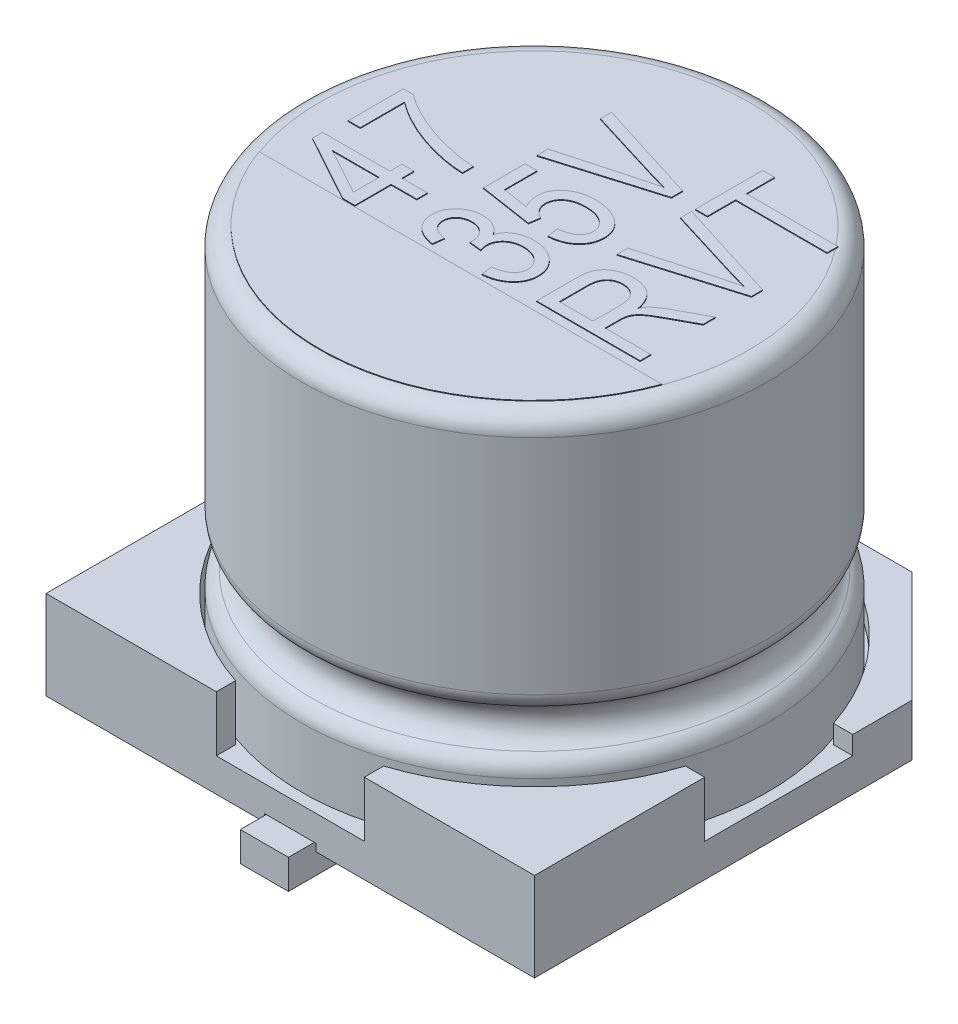
from build123d import *

# Parameters (mm, degrees)
SKETCH1_W                = 6.6
SKETCH1_H                = 6.6
BOSS_EXTRUDE1_DEPTH      = 1.2
CUT_EXTRUDE1_DEPTH       = 0.75
SKETCH3_W                = 3.3
SKETCH3_H                = 0.5
CUT_EXTRUDE2_DEPTH       = 5.902040392
CUT_EXTRUDE2_DEPTH_BACK  = 5.902040392
CHAMFER1_SIZE            = 1.5
CUT_EXTRUDE3_DEPTH       = 0.1
BOSS_EXTRUDE4_DEPTH      = 0.3
BOSS_EXTRUDE4_DEPTH_BACK = 0.1
SKETCH8_R                = 0.5
BOSS_EXTRUDE5_DEPTH      = 0.3
BOSS_EXTRUDE7_DEPTH      = 0.01


with BuildPart() as part:
    # Sketch1 → Boss-Extrude1 (new body)
    with BuildSketch(Plane(origin=(0, 0.3, 0), x_dir=(1, 0, 0), z_dir=(0, 1, 0))):
        Rectangle(SKETCH1_W, SKETCH1_H)
    extrude(amount=BOSS_EXTRUDE1_DEPTH)

    # Sketch2 → Cut-Extrude1 (cut)
    with BuildSketch(Plane(origin=(0, 1.5, 0), x_dir=(1, 0, 0), z_dir=(0, 1, 0))):
        with BuildLine():
            Line((-3.3, 1), (-3.039736831, 1))
            ThreePointArc((-3.039736831, 1), (-2.2627417, 2.2627417), (-1, 3.039736831))
            Line((-1, 3.039736831), (-1, 3.3))
            Line((-1, 3.3), (1, 3.3))
            Line((1, 3.3), (1, 3.039736831))
            ThreePointArc((1, 3.039736831), (2.2627417, 2.2627417), (3.039736831, 1))
            Line((3.039736831, 1), (3.3, 1))
            Line((3.3, 1), (3.3, -1))
            Line((3.3, -1), (3.039736831, -1))
            ThreePointArc((3.039736831, -1), (2.2627417, -2.2627417), (1, -3.039736831))
            Line((1, -3.039736831), (1, -3.3))
            Line((1, -3.3), (-1, -3.3))
            Line((-1, -3.3), (-1, -3.039736831))
            ThreePointArc((-1, -3.039736831), (-2.2627417, -2.2627417), (-3.039736831, -1))
            Line((-3.039736831, -1), (-3.3, -1))
            Line((-3.3, -1), (-3.3, 1))
        make_face()
    extrude(amount=-CUT_EXTRUDE1_DEPTH, mode=Mode.SUBTRACT)

    # Sketch3 → Cut-Extrude2 (cut, two sides)
    with BuildSketch(Plane(origin=(0, 0, 0), x_dir=(0, 0, -1), z_dir=(1, 0, 0))) as cut_extrude2_sk:
        with Locations((1.65, 1.25)):
            Rectangle(SKETCH3_W, SKETCH3_H)
    extrude(amount=CUT_EXTRUDE2_DEPTH, mode=Mode.SUBTRACT)
    extrude(cut_extrude2_sk.sketch, amount=-CUT_EXTRUDE2_DEPTH_BACK, mode=Mode.SUBTRACT)

    # Chamfer1
    chamfer1_edges = [part.edges().sort_by_distance(p)[0] for p in [
        (3.3, 0.65, -3.3),
        (-3.3, 0.65, -3.3),
    ]]
    chamfer(chamfer1_edges, length=CHAMFER1_SIZE)

    # Sketch7 → Cut-Extrude3 (cut)
    with BuildSketch(Plane.XZ.offset(-0.3)):
        with BuildLine():
            Line((-0.35, 3.3), (0.35, 3.3))
            Line((0.35, 3.3), (0.498675617, 1.261367968))
            ThreePointArc((0.498675617, 1.261367968), (0, 0.725), (-0.498675617, 1.261367968))
            Line((-0.498675617, 1.261367968), (-0.35, 3.3))
        make_face()
        with BuildLine():
            Line((-0.35, -3.3), (0.35, -3.3))
            Line((0.35, -3.3), (0.498675617, -1.261367968))
            ThreePointArc((0.498675617, -1.261367968), (0, -0.725), (-0.498675617, -1.261367968))
            Line((-0.498675617, -1.261367968), (-0.35, -3.3))
        make_face()
    extrude(amount=-CUT_EXTRUDE3_DEPTH, mode=Mode.SUBTRACT)

    # Sketch6 → Boss-Extrude4 (add, two sides)
    with BuildSketch(Plane.XZ.offset(-0.3)) as boss_extrude4_sk:
        with BuildLine():
            Line((-0.325, -1.225), (-0.325, -3.65))
            Line((-0.325, -3.65), (0.325, -3.65))
            Line((0.325, -3.65), (0.325, -1.225))
            ThreePointArc((0.325, -1.225), (0, -0.9), (-0.325, -1.225))
        make_face()
        with BuildLine():
            Line((-0.325, 1.225), (-0.325, 3.65))
            Line((-0.325, 3.65), (0.325, 3.65))
            Line((0.325, 3.65), (0.325, 1.225))
            ThreePointArc((0.325, 1.225), (0, 0.9), (-0.325, 1.225))
        make_face()
    extrude(amount=BOSS_EXTRUDE4_DEPTH)
    extrude(boss_extrude4_sk.sketch, amount=-BOSS_EXTRUDE4_DEPTH_BACK)

    # Sketch8 → Boss-Extrude5 (add)
    with BuildSketch(Plane.XZ.offset(-0.3)):
        with Locations(Location((-2, 2, 0), (0, 0, 270))):
            Circle(SKETCH8_R)
        with Locations(Location((2, 2, 0), (0, 0, 270))):
            Circle(SKETCH8_R)
        with Locations(Location((2, -2, 0), (0, 0, 270))):
            Circle(SKETCH8_R)
        with Locations(Location((-2, -2, 0), (0, 0, 270))):
            Circle(SKETCH8_R)
    extrude(amount=BOSS_EXTRUDE5_DEPTH)


with BuildPart() as body_2:
    # Sketch4 → Revolve1 (revolve)
    with BuildSketch(Plane(origin=(0, 0, 0), x_dir=(0, 0, -1), z_dir=(1, 0, 0)), mode=Mode.PRIVATE) as revolve1_sk:
        with BuildLine():
            Line((0, 0.75), (0, 5.8))
            Line((0, 5.8), (-2.9, 5.8))
            ThreePointArc((-2.9, 5.8), (-3.076776695, 5.726776695), (-3.15, 5.55))
            Line((-3.15, 5.55), (-3.15, 2.539897949))
            ThreePointArc((-3.15, 2.539897949), (-3.113200716, 2.409339707), (-3.013636364, 2.317217063))
            ThreePointArc((-3.013636364, 2.317217063), (-2.85, 2.05), (-3.013636364, 1.782782937))
            ThreePointArc((-3.013636364, 1.782782937), (-3.113200716, 1.690660293), (-3.15, 1.560102051))
            Line((-3.15, 1.560102051), (-3.15, 0.75))
            Line((-3.15, 0.75), (0, 0.75))
        make_face()
    revolve(revolve1_sk.sketch.rotate(Axis((0, 0, 0), (0, 1, 0)), 180), axis=Axis((0, 0, 0), (0, 1, 0)))

    # Sketch10 → Boss-Extrude7 (add)
    with BuildSketch(Plane(origin=(0, 5.8, 0), x_dir=(1, 0, 0), z_dir=(0, 1, 0))):
        with BuildLine():
            Line((-2.722131518, -1), (2.722131518, -1))
            ThreePointArc((2.722131518, -1), (0, -2.9), (-2.722131518, -1))
        make_face()
        Polygon((-1.1, -0.490909091), (-1.445454545, -0.490909091), (-1.445454545, -0.981818182), (-1.609090909, -0.981818182), (-2.518181818, -0.482670455), (-2.518181818, -0.345454545), (-1.609090909, -0.345454545), (-1.609090909, -0.181818182), (-1.445454545, -0.181818182), (-1.445454545, -0.345454545), (-1.1, -0.345454545), align=None)
        Polygon((-1.609090909, -0.490909091), (-2.241761364, -0.490909091), (-1.609090909, -0.838352273), align=None, mode=Mode.SUBTRACT)
        with BuildLine():
            Line((-2.318181818, -0.036363636), (-2.481818182, -0.036363636))
            Line((-2.481818182, -0.036363636), (-2.481818182, 0.709090909))
            Line((-2.481818182, 0.709090909), (-2.348011364, 0.709090909))
            add(Edge.make_bspline(
                [(-2.348011364, 0.709090909), (-2.329493997, 0.695259816), (-2.291802758, 0.667107268), (-2.231511589, 0.627736674), (-2.167300458, 0.589447284), (-2.099115474, 0.552202178), (-2.026735965, 0.516442976), (-1.950395077, 0.481792677), (-1.869863353, 0.448671938), (-1.786180255, 0.416771358), (-1.700509186, 0.387072726), (-1.614166454, 0.360699392), (-1.527962748, 0.337560436), (-1.441958888, 0.318119267), (-1.356259293, 0.301430866), (-1.270766825, 0.288433289), (-1.185381408, 0.278624638), (-1.128427711, 0.274690798), (-1.1, 0.272727273)],
                knots=[0, 0, 0, 0, 0.828228242, 1.685820058, 2.579325365, 3.507361607, 4.469713273, 5.472243924, 6.511632332, 7.590183537, 8.68180921, 9.76082494, 10.825356942, 11.880104434, 12.920528634, 13.95402052, 14.978775448, 16, 16, 16, 16], degree=3))
            Line((-1.1, 0.272727273), (-1.1, 0.127272727))
            add(Edge.make_bspline(
                [(-1.1, 0.127272727), (-1.114968384, 0.127721783), (-1.145503887, 0.128637858), (-1.192187637, 0.132321595), (-1.240736039, 0.136926159), (-1.291101377, 0.14395977), (-1.343309321, 0.152404131), (-1.397339203, 0.16282712), (-1.453308412, 0.174269157), (-1.530001628, 0.192613669), (-1.62599912, 0.218383212), (-1.739052852, 0.255716866), (-1.849665888, 0.297377526), (-1.956248385, 0.345139752), (-2.057722591, 0.395822213), (-2.151901767, 0.449612447), (-2.239097534, 0.503996466), (-2.292310728, 0.544126176), (-2.318181818, 0.563636364)],
                knots=[0, 0, 0, 0, 0.547560405, 1.117023226, 1.712128439, 2.330702075, 2.976322001, 3.646013224, 4.342857794, 5.065247493, 6.529539093, 7.976213993, 9.417556904, 10.850065343, 12.245478746, 13.563746768, 14.815546979, 16, 16, 16, 16], degree=3))
            Line((-2.318181818, 0.563636364), (-2.318181818, -0.036363636))
        make_face()
        with BuildLine():
            Line((0.218181818, -0.927272727), (0.2, -0.781818182))
            add(Edge.make_bspline(
                [(0.2, -0.781818182), (0.211007106, -0.779942216), (0.232455925, -0.776286646), (0.263321691, -0.769094104), (0.292204025, -0.761244122), (0.31883103, -0.75214582), (0.343462791, -0.742228405), (0.365942251, -0.73123066), (0.386265646, -0.718934775), (0.404444756, -0.705643407), (0.420565669, -0.691315503), (0.434522787, -0.67601624), (0.446306126, -0.659602334), (0.456112377, -0.642230253), (0.463387067, -0.623625086), (0.468939102, -0.604152393), (0.472027052, -0.583526059), (0.472490475, -0.5694225), (0.472727273, -0.562215909)],
                knots=[0, 0, 0, 0, 1.392235382, 2.712957193, 3.95076201, 5.123471921, 6.220028287, 7.260520794, 8.240826993, 9.178593426, 10.065213643, 10.926376853, 11.755607984, 12.580369742, 13.407158359, 14.241002189, 15.101193065, 16, 16, 16, 16], degree=3))
            add(Edge.make_bspline(
                [(0.472727273, -0.562215909), (0.472577298, -0.554333745), (0.472282519, -0.538841217), (0.467891068, -0.516137974), (0.461895744, -0.494080521), (0.452557801, -0.473049195), (0.441083833, -0.452673681), (0.427240736, -0.432928372), (0.410127195, -0.414589557), (0.391315379, -0.396729975), (0.370429846, -0.380261991), (0.347624201, -0.366047226), (0.323284305, -0.354172655), (0.297651287, -0.343941869), (0.270175187, -0.336935551), (0.24151094, -0.330948508), (0.211140838, -0.327994951), (0.190440289, -0.327517474), (0.179829545, -0.327272727)],
                knots=[0, 0, 0, 0, 0.90401877, 1.776864238, 2.648081008, 3.525187418, 4.41175602, 5.332444618, 6.287459433, 7.287987893, 8.31086095, 9.337199425, 10.368656826, 11.419214808, 12.501240718, 13.621372252, 14.780756564, 16, 16, 16, 16], degree=3))
            add(Edge.make_bspline(
                [(0.179829545, -0.327272727), (0.169880445, -0.327530349), (0.150509863, -0.328031929), (0.122176015, -0.330790698), (0.095332464, -0.335845419), (0.070052559, -0.343397933), (0.045946798, -0.352341479), (0.023507707, -0.363757347), (0.00260552, -0.377228214), (-0.016606513, -0.392470321), (-0.033934824, -0.409291249), (-0.049309229, -0.427056412), (-0.062233922, -0.445902217), (-0.072512687, -0.465824635), (-0.080790079, -0.486542866), (-0.086829101, -0.50823826), (-0.09027555, -0.530949186), (-0.090695173, -0.546389907), (-0.090909091, -0.554261364)],
                knots=[0, 0, 0, 0, 1.208597586, 2.353100882, 3.45394355, 4.52041929, 5.55433039, 6.572835576, 7.571467818, 8.570232532, 9.546354476, 10.500752408, 11.419554319, 12.314725937, 13.218209175, 14.125127028, 15.044216874, 16, 16, 16, 16], degree=3))
            add(Edge.make_bspline(
                [(-0.090909091, -0.554261364), (-0.090685115, -0.561378176), (-0.09020766, -0.576549262), (-0.086078588, -0.600438295), (-0.080275224, -0.626876002), (-0.074580449, -0.64502036), (-0.071590909, -0.654545455)],
                knots=[0, 0, 0, 0, 0.832645691, 1.774971563, 2.831945141, 4, 4, 4, 4], degree=3))
            Line((-0.071590909, -0.654545455), (-0.236363636, -0.636363636))
            Line((-0.236363636, -0.636363636), (-0.234375, -0.614488636))
            add(Edge.make_bspline(
                [(-0.234375, -0.614488636), (-0.234471562, -0.606047534), (-0.234659986, -0.58957609), (-0.238100642, -0.565479821), (-0.242716286, -0.542518495), (-0.249520119, -0.520775269), (-0.258591189, -0.500475604), (-0.268853361, -0.480958247), (-0.281935977, -0.463149348), (-0.296240178, -0.446273642), (-0.31255473, -0.431386896), (-0.32979079, -0.417768621), (-0.348738456, -0.406792048), (-0.36885059, -0.39747845), (-0.390353615, -0.39058779), (-0.41303568, -0.38527953), (-0.437057369, -0.382594554), (-0.453498447, -0.382081401), (-0.461931818, -0.381818182)],
                knots=[0, 0, 0, 0, 1.104751502, 2.155743671, 3.182513959, 4.171256571, 5.132373004, 6.092768569, 7.053244257, 8.020744794, 8.986334532, 9.941668794, 10.892724274, 11.847575109, 12.840124028, 13.845307576, 14.89476101, 16, 16, 16, 16], degree=3))
            add(Edge.make_bspline(
                [(-0.461931818, -0.381818182), (-0.477042, -0.382465495), (-0.506081067, -0.383709516), (-0.547490028, -0.393407956), (-0.584269346, -0.410010102), (-0.615585748, -0.43319223), (-0.640886334, -0.460842938), (-0.659391316, -0.492035416), (-0.670665785, -0.526328903), (-0.672031656, -0.550294637), (-0.672727273, -0.5625)],
                knots=[0, 0, 0, 0, 1.16832052, 2.245303051, 3.268291818, 4.269210926, 5.239185917, 6.148985104, 7.05730787, 8, 8, 8, 8], degree=3))
            add(Edge.make_bspline(
                [(-0.672727273, -0.5625), (-0.672136462, -0.575177442), (-0.670987129, -0.599839461), (-0.660065857, -0.635121915), (-0.643265499, -0.667459622), (-0.62338947, -0.691252383), (-0.604305971, -0.708061423), (-0.588001403, -0.719706286), (-0.570101021, -0.730321018), (-0.550244964, -0.73920806), (-0.528993695, -0.74778534), (-0.505599424, -0.753845761), (-0.480781666, -0.75990119), (-0.463475995, -0.762364948), (-0.454545455, -0.763636364)],
                knots=[0, 0, 0, 0, 1.388978158, 2.702043981, 4.01873002, 5.370445164, 6.077879322, 6.808188353, 7.568116439, 8.359222831, 9.195597867, 10.081410868, 11.009917745, 12, 12, 12, 12], degree=3))
            Line((-0.454545455, -0.763636364), (-0.472727273, -0.909090909))
            add(Edge.make_bspline(
                [(-0.472727273, -0.909090909), (-0.486588422, -0.906709187), (-0.513627385, -0.902063157), (-0.552534962, -0.892356516), (-0.588882675, -0.880804326), (-0.622470375, -0.866817395), (-0.653589647, -0.850935865), (-0.682109165, -0.83296739), (-0.708216168, -0.813146008), (-0.731189578, -0.790783101), (-0.751650837, -0.767015095), (-0.769321558, -0.741828188), (-0.78453133, -0.715671444), (-0.796784585, -0.688113739), (-0.806500844, -0.659413834), (-0.813300208, -0.62942803), (-0.817319761, -0.5983104), (-0.817891717, -0.577189816), (-0.818181818, -0.566477273)],
                knots=[0, 0, 0, 0, 1.259750421, 2.457396855, 3.589696629, 4.673763457, 5.713494597, 6.716289503, 7.690389722, 8.644478697, 9.583164327, 10.496506905, 11.397350125, 12.289843847, 13.194037124, 14.107891875, 15.040306322, 16, 16, 16, 16], degree=3))
            add(Edge.make_bspline(
                [(-0.818181818, -0.566477273), (-0.817849499, -0.555189393), (-0.817195712, -0.532982213), (-0.81216052, -0.500348199), (-0.804360335, -0.468940312), (-0.792829686, -0.438990922), (-0.778255688, -0.410272016), (-0.760170015, -0.382972618), (-0.7391088, -0.356770776), (-0.715081364, -0.332176141), (-0.688496941, -0.309862399), (-0.659952473, -0.290196602), (-0.629838405, -0.273227531), (-0.597699986, -0.259960811), (-0.564045505, -0.249401853), (-0.528783494, -0.241757044), (-0.491794021, -0.237063148), (-0.466586203, -0.236600346), (-0.453693182, -0.236363636)],
                knots=[0, 0, 0, 0, 0.987388499, 1.942536239, 2.883158237, 3.814277833, 4.744511983, 5.696058098, 6.674468722, 7.682403848, 8.699933891, 9.706744222, 10.712052869, 11.718590333, 12.743383256, 13.79503062, 14.872226231, 16, 16, 16, 16], degree=3))
            add(Edge.make_bspline(
                [(-0.453693182, -0.236363636), (-0.438125528, -0.236801256), (-0.407722128, -0.237655922), (-0.363619433, -0.245894), (-0.322243567, -0.258967805), (-0.283869742, -0.277202539), (-0.248695107, -0.299925141), (-0.217581104, -0.327217825), (-0.190001883, -0.358366016), (-0.175513292, -0.382049729), (-0.168181818, -0.394034091)],
                knots=[0, 0, 0, 0, 1.090109576, 2.128968013, 3.132278696, 4.123864162, 5.09769889, 6.057339906, 7.016980922, 8, 8, 8, 8], degree=3))
            add(Edge.make_bspline(
                [(-0.168181818, -0.394034091), (-0.164794643, -0.383025672), (-0.158176533, -0.361516618), (-0.143272883, -0.331843256), (-0.125965116, -0.304786209), (-0.105205177, -0.280610246), (-0.080986041, -0.259108107), (-0.053139537, -0.239908092), (-0.021399527, -0.223411796), (0.013442898, -0.208508231), (0.051362925, -0.196828759), (0.091602413, -0.187855507), (0.134149227, -0.182767109), (0.163244427, -0.182139281), (0.178125, -0.181818182)],
                knots=[0, 0, 0, 0, 0.945190562, 1.846782401, 2.71900073, 3.580139159, 4.456653473, 5.37426406, 6.352713278, 7.392141409, 8.485180558, 9.608884637, 10.777077804, 12, 12, 12, 12], degree=3))
            add(Edge.make_bspline(
                [(0.178125, -0.181818182), (0.193956497, -0.182100114), (0.224864479, -0.182650533), (0.270088329, -0.188280689), (0.313135099, -0.197047206), (0.35415735, -0.209071993), (0.392766093, -0.22525971), (0.429357749, -0.244501126), (0.463535233, -0.267692236), (0.495224314, -0.294050206), (0.523859571, -0.322740148), (0.549309456, -0.352951249), (0.570155465, -0.385048482), (0.588203791, -0.417955902), (0.601450887, -0.452723838), (0.611241954, -0.488666444), (0.616996865, -0.526141121), (0.617783261, -0.551590514), (0.618181818, -0.564488636)],
                knots=[0, 0, 0, 0, 1.16811134, 2.280514916, 3.358044357, 4.408548324, 5.43018962, 6.443354211, 7.455384821, 8.473000684, 9.481330986, 10.444351977, 11.382702375, 12.302115503, 13.209492159, 14.121756026, 15.048078649, 16, 16, 16, 16], degree=3))
            add(Edge.make_bspline(
                [(0.618181818, -0.564488636), (0.617863516, -0.576438512), (0.617236528, -0.599977211), (0.611995991, -0.634554935), (0.603386915, -0.667629385), (0.591834099, -0.699493451), (0.576205806, -0.729747753), (0.557507399, -0.758714121), (0.535301773, -0.786291731), (0.509949449, -0.812228909), (0.481552485, -0.835919572), (0.450949567, -0.857456509), (0.41801359, -0.876264186), (0.382414632, -0.891873127), (0.344657211, -0.904836633), (0.304626921, -0.91545202), (0.26225395, -0.923158475), (0.233076611, -0.925882258), (0.218181818, -0.927272727)],
                knots=[0, 0, 0, 0, 0.959215385, 1.889449177, 2.800558469, 3.700364268, 4.604976927, 5.528817283, 6.464628809, 7.443299003, 8.436397546, 9.430019983, 10.444889234, 11.476401659, 12.54654308, 13.647683262, 14.799161616, 16, 16, 16, 16], degree=3))
        make_face()
        with BuildLine():
            Line((0.218181818, -0.036363636), (0.2, 0.109090909))
            add(Edge.make_bspline(
                [(0.2, 0.109090909), (0.211101971, 0.110567587), (0.232737788, 0.113445378), (0.263885694, 0.119848382), (0.293064038, 0.126930845), (0.319651618, 0.136285915), (0.34447028, 0.146000707), (0.366780938, 0.157754603), (0.387216311, 0.170429338), (0.405044464, 0.184825644), (0.42111939, 0.19975374), (0.434636833, 0.215785653), (0.446561389, 0.232076172), (0.456229143, 0.249117635), (0.463723293, 0.266844238), (0.468775385, 0.285197267), (0.472033163, 0.304051607), (0.472494528, 0.316842721), (0.472727273, 0.323295455)],
                knots=[0, 0, 0, 0, 1.411589299, 2.750942728, 4.00771248, 5.193274551, 6.301848483, 7.364530321, 8.36815806, 9.328452501, 10.249032995, 11.129646394, 11.967965374, 12.7913576, 13.594060915, 14.387835106, 15.186711129, 16, 16, 16, 16], degree=3))
            add(Edge.make_bspline(
                [(0.472727273, 0.323295455), (0.47246113, 0.331363756), (0.471934427, 0.347331097), (0.46751459, 0.370816108), (0.460368895, 0.393421364), (0.450386963, 0.415271865), (0.43708047, 0.435936311), (0.421405758, 0.456119122), (0.402468066, 0.474980646), (0.381218628, 0.493183371), (0.357552586, 0.510017788), (0.331144397, 0.524080821), (0.302921326, 0.536308638), (0.27269317, 0.546702043), (0.240203605, 0.554209971), (0.20572194, 0.559481998), (0.169202922, 0.563055128), (0.1441377, 0.563438993), (0.13125, 0.563636364)],
                knots=[0, 0, 0, 0, 0.833503236, 1.64952068, 2.460650161, 3.279715081, 4.124353123, 4.995793989, 5.916428404, 6.881576056, 7.886415737, 8.911413223, 9.967990459, 11.063833818, 12.210651719, 13.409634283, 14.668120429, 16, 16, 16, 16], degree=3))
            add(Edge.make_bspline(
                [(0.13125, 0.563636364), (0.119216027, 0.563411231), (0.095769358, 0.56297259), (0.061609862, 0.559772504), (0.029473354, 0.554831228), (-0.000594739, 0.547469608), (-0.028423842, 0.537659446), (-0.054490961, 0.526502629), (-0.078298563, 0.512722984), (-0.099725125, 0.496779871), (-0.119111641, 0.479625248), (-0.135710672, 0.460896308), (-0.149925684, 0.441323642), (-0.161929936, 0.420707247), (-0.170475105, 0.398657339), (-0.177295763, 0.375820096), (-0.180872766, 0.351720796), (-0.181499254, 0.335331824), (-0.181818182, 0.326988636)],
                knots=[0, 0, 0, 0, 1.312040837, 2.556345105, 3.737883698, 4.854849349, 5.925960309, 6.952388988, 7.9424386, 8.917239489, 9.860521384, 10.760061641, 11.639947922, 12.495504232, 13.352616949, 14.212152034, 15.089854369, 16, 16, 16, 16], degree=3))
            add(Edge.make_bspline(
                [(-0.181818182, 0.326988636), (-0.181386991, 0.31691141), (-0.180526809, 0.296808367), (-0.173354012, 0.267203557), (-0.161919921, 0.238576183), (-0.145949551, 0.211277017), (-0.125781986, 0.186087196), (-0.101844533, 0.163424776), (-0.074502628, 0.143327785), (-0.054133578, 0.132693693), (-0.04375, 0.127272727)],
                knots=[0, 0, 0, 0, 0.943121662, 1.881431981, 2.836990949, 3.823036868, 4.833137184, 5.849762362, 6.903868453, 8, 8, 8, 8], degree=3))
            Line((-0.04375, 0.127272727), (-0.064488636, -0.018181818))
            Line((-0.064488636, -0.018181818), (-0.781818182, 0.090909091))
            Line((-0.781818182, 0.090909091), (-0.781818182, 0.654545455))
            Line((-0.781818182, 0.654545455), (-0.618181818, 0.654545455))
            Line((-0.618181818, 0.654545455), (-0.618181818, 0.212784091))
            Line((-0.618181818, 0.212784091), (-0.272443182, 0.160227273))
            add(Edge.make_bspline(
                [(-0.272443182, 0.160227273), (-0.280823021, 0.176613081), (-0.297407403, 0.209041926), (-0.314678944, 0.260640587), (-0.32533713, 0.313667947), (-0.326625365, 0.349571453), (-0.327272727, 0.367613636)],
                knots=[0, 0, 0, 0, 1.017619267, 2.013951072, 3.001973272, 4, 4, 4, 4], degree=3))
            add(Edge.make_bspline(
                [(-0.327272727, 0.367613636), (-0.326874523, 0.378906499), (-0.326083106, 0.401350674), (-0.320235417, 0.434343157), (-0.310874813, 0.466250024), (-0.297294668, 0.496922513), (-0.279916146, 0.526376693), (-0.258874387, 0.554832977), (-0.234130638, 0.58215363), (-0.205438517, 0.607756331), (-0.173874347, 0.631620275), (-0.139218461, 0.652454829), (-0.10193904, 0.670137284), (-0.061857834, 0.684168416), (-0.019379192, 0.695726579), (0.025894119, 0.703532212), (0.073772199, 0.708019966), (0.106524397, 0.708728234), (0.123295455, 0.709090909)],
                knots=[0, 0, 0, 0, 0.861018809, 1.711245113, 2.547675859, 3.391805506, 4.262674834, 5.151129072, 6.086914488, 7.068866089, 8.080081396, 9.100796714, 10.1476286, 11.221399762, 12.335728169, 13.501851446, 14.720800604, 16, 16, 16, 16], degree=3))
            add(Edge.make_bspline(
                [(0.123295455, 0.709090909), (0.139972763, 0.708744866), (0.172829781, 0.708063103), (0.221182639, 0.703234952), (0.267685748, 0.694930211), (0.312341106, 0.683620509), (0.355233532, 0.669108797), (0.396299037, 0.651153258), (0.435499753, 0.629784545), (0.472612172, 0.605560487), (0.506510629, 0.57857772), (0.53647709, 0.549082485), (0.561857129, 0.517280497), (0.582560215, 0.483088947), (0.598604448, 0.446704241), (0.609942787, 0.408034652), (0.616952086, 0.367110572), (0.617766217, 0.339043658), (0.618181818, 0.324715909)],
                knots=[0, 0, 0, 0, 1.144492614, 2.254837035, 3.330813134, 4.383755227, 5.413414698, 6.434919789, 7.455680344, 8.474121079, 9.472858394, 10.424138735, 11.353862604, 12.257787762, 13.159841921, 14.074912736, 15.017271142, 16, 16, 16, 16], degree=3))
            add(Edge.make_bspline(
                [(0.618181818, 0.324715909), (0.617828765, 0.312771431), (0.617133725, 0.289256917), (0.612395275, 0.254615174), (0.603577826, 0.221636349), (0.592442177, 0.189715236), (0.577096784, 0.15959834), (0.55888353, 0.130664995), (0.537105731, 0.103295459), (0.512134892, 0.077568051), (0.484458274, 0.053758215), (0.454005872, 0.032531418), (0.420992011, 0.014069776), (0.385306503, -0.001590372), (0.347111633, -0.014252186), (0.306479895, -0.024498815), (0.263297216, -0.032285998), (0.233456651, -0.03498306), (0.218181818, -0.036363636)],
                knots=[0, 0, 0, 0, 0.958689857, 1.887326147, 2.797936266, 3.6946441, 4.595336751, 5.504073741, 6.434636212, 7.396724143, 8.377688541, 9.360182663, 10.370759081, 11.408658253, 12.482955239, 13.5963024, 14.769591684, 16, 16, 16, 16], degree=3))
        make_face()
        with BuildLine():
            Line((0.6, 1.250852273), (-0.8, 0.832102273))
            Line((-0.8, 0.832102273), (-0.8, 0.981818182))
            Line((-0.8, 0.981818182), (0.215625, 1.261931818))
            add(Edge.make_bspline(
                [(0.215625, 1.261931818), (0.23502513, 1.267188611), (0.273113627, 1.277509333), (0.329419911, 1.291882434), (0.383540048, 1.305617864), (0.419023676, 1.314057553), (0.436363636, 1.318181818)],
                knots=[0, 0, 0, 0, 1.058778416, 2.078711773, 3.061114545, 4, 4, 4, 4], degree=3))
            add(Edge.make_bspline(
                [(0.436363636, 1.318181818), (0.400128509, 1.327526981), (0.326165891, 1.346602192), (0.252964299, 1.368417642), (0.215625, 1.379545455)],
                knots=[0, 0, 0, 0, 0.979822753, 2, 2, 2, 2], degree=3))
            Line((0.215625, 1.379545455), (-0.8, 1.690909091))
            Line((-0.8, 1.690909091), (-0.8, 1.842045455))
            Line((-0.8, 1.842045455), (0.6, 1.401136364))
            Line((0.6, 1.401136364), (0.6, 1.250852273))
        make_face()
        with BuildLine():
            Line((2.3, -0.872727273), (0.9, -0.872727273))
            Line((0.9, -0.872727273), (0.9, -0.358522727))
            add(Edge.make_bspline(
                [(0.9, -0.358522727), (0.900073763, -0.345546017), (0.900216539, -0.320428259), (0.902308959, -0.284044497), (0.905344787, -0.250202662), (0.909579597, -0.219012834), (0.914777868, -0.190483154), (0.921766894, -0.16473241), (0.929434889, -0.141402667), (0.942097141, -0.11394169), (0.962104286, -0.08285306), (0.991986148, -0.049045543), (1.029113573, -0.019546227), (1.071726678, 0.006727276), (1.11958402, 0.028297408), (1.17177175, 0.043578157), (1.22760849, 0.052802429), (1.266062455, 0.053954341), (1.285795455, 0.054545455)],
                knots=[0, 0, 0, 0, 0.957632509, 1.853596319, 2.688865688, 3.464800978, 4.176232129, 4.827248354, 5.432859936, 5.986426289, 7.054779681, 8.148885667, 9.301586196, 10.541074307, 11.836203864, 13.163061816, 14.544199576, 16, 16, 16, 16], degree=3))
            add(Edge.make_bspline(
                [(1.285795455, 0.054545455), (1.298871698, 0.054235333), (1.32441369, 0.053629569), (1.361855278, 0.049987367), (1.397440244, 0.043563031), (1.430988976, 0.034018043), (1.462814114, 0.022553984), (1.492482956, 0.007839851), (1.520425409, -0.009159596), (1.546408208, -0.028871174), (1.570251677, -0.051075165), (1.592091252, -0.075549512), (1.611022928, -0.102851103), (1.628180904, -0.132133088), (1.642985373, -0.163902878), (1.65548257, -0.198004739), (1.665367052, -0.234558689), (1.67023708, -0.259813647), (1.672727273, -0.272727273)],
                knots=[0, 0, 0, 0, 1.121876415, 2.19137531, 3.223949102, 4.219388443, 5.180726412, 6.121767895, 7.055309798, 7.98310721, 8.914383918, 9.846793912, 10.791230962, 11.759648879, 12.755485972, 13.793860249, 14.871933835, 16, 16, 16, 16], degree=3))
            add(Edge.make_bspline(
                [(1.672727273, -0.272727273), (1.677972871, -0.263164174), (1.687983581, -0.244913937), (1.704620081, -0.220357649), (1.720557857, -0.198837772), (1.732437343, -0.186905744), (1.738068182, -0.18125)],
                knots=[0, 0, 0, 0, 1.159024517, 2.21188481, 3.152438931, 4, 4, 4, 4], degree=3))
            add(Edge.make_bspline(
                [(1.738068182, -0.18125), (1.751761893, -0.169905132), (1.779303299, -0.147087825), (1.82324216, -0.115808927), (1.868950866, -0.085847863), (1.901104584, -0.068253316), (1.917329545, -0.059375)],
                knots=[0, 0, 0, 0, 0.982253192, 1.975551771, 2.978451105, 4, 4, 4, 4], degree=3))
            Line((1.917329545, -0.059375), (2.3, 0.145454545))
            Line((2.3, 0.145454545), (2.3, -0.019886364))
            Line((2.3, -0.019886364), (2.000568182, -0.181534091))
            add(Edge.make_bspline(
                [(2.000568182, -0.181534091), (1.986528238, -0.189064398), (1.959673176, -0.203468078), (1.921542639, -0.224844268), (1.887155621, -0.244716202), (1.856473931, -0.26304488), (1.829837697, -0.28011911), (1.806835821, -0.29541567), (1.787807022, -0.309583774), (1.767901985, -0.326061224), (1.747867101, -0.345925096), (1.727397014, -0.368993525), (1.711579168, -0.392199546), (1.699513707, -0.415799766), (1.691569692, -0.441785471), (1.685622134, -0.471064256), (1.682387461, -0.504948189), (1.682015972, -0.528971003), (1.681818182, -0.541761364)],
                knots=[0, 0, 0, 0, 1.483604313, 2.837780862, 4.070509745, 5.182094193, 6.165504003, 7.016659521, 7.753887315, 8.373758725, 9.421416007, 10.377927395, 11.24132908, 12.030078718, 12.836042303, 13.763032878, 14.808981517, 16, 16, 16, 16], degree=3))
            Line((1.681818182, -0.541761364), (1.681818182, -0.727272727))
            Line((1.681818182, -0.727272727), (2.3, -0.727272727))
            Line((2.3, -0.727272727), (2.3, -0.872727273))
        make_face()
        with BuildLine():
            Line((1.518181818, -0.727272727), (1.518181818, -0.386079545))
            add(Edge.make_bspline(
                [(1.518181818, -0.386079545), (1.51784038, -0.368551478), (1.517200491, -0.33570217), (1.512950466, -0.289746201), (1.505260087, -0.250520807), (1.494057811, -0.217296065), (1.479219373, -0.188958415), (1.460827249, -0.164309705), (1.438869635, -0.14255013), (1.413289498, -0.12443297), (1.385178927, -0.108949222), (1.354131271, -0.098784902), (1.321145845, -0.091792043), (1.298334339, -0.0912082), (1.286647727, -0.090909091)],
                knots=[0, 0, 0, 0, 1.473137061, 2.760802605, 3.873686451, 4.825077919, 5.697275026, 6.550455577, 7.400251438, 8.283812568, 9.177530931, 10.086115457, 11.019493646, 12, 12, 12, 12], degree=3))
            add(Edge.make_bspline(
                [(1.286647727, -0.090909091), (1.278213117, -0.091167916), (1.261769623, -0.091672503), (1.237673197, -0.0944289), (1.215017199, -0.0995137), (1.19372088, -0.106728841), (1.173827875, -0.115709596), (1.155330151, -0.126983949), (1.138402828, -0.140382054), (1.122625811, -0.155455071), (1.108512425, -0.172607295), (1.096745483, -0.19208158), (1.086418458, -0.213266004), (1.077823559, -0.236448353), (1.071407677, -0.261698229), (1.066974643, -0.288890824), (1.064002815, -0.317926589), (1.063761011, -0.337965593), (1.063636364, -0.348295455)],
                knots=[0, 0, 0, 0, 1.044922679, 2.037104192, 2.998871072, 3.914999749, 4.817741419, 5.696780486, 6.590716951, 7.486574954, 8.395164589, 9.332593663, 10.297787276, 11.310892337, 12.389055078, 13.518989792, 14.721069654, 16, 16, 16, 16], degree=3))
            Line((1.063636364, -0.348295455), (1.063636364, -0.727272727))
            Line((1.063636364, -0.727272727), (1.518181818, -0.727272727))
        make_face(mode=Mode.SUBTRACT)
        with BuildLine():
            Line((2.3, 0.632670455), (0.9, 0.213920455))
            Line((0.9, 0.213920455), (0.9, 0.363636364))
            Line((0.9, 0.363636364), (1.915625, 0.64375))
            add(Edge.make_bspline(
                [(1.915625, 0.64375), (1.93502513, 0.649006793), (1.973113627, 0.659327515), (2.029419911, 0.673700615), (2.083540048, 0.687436046), (2.119023676, 0.695875735), (2.136363636, 0.7)],
                knots=[0, 0, 0, 0, 1.058778416, 2.078711773, 3.061114545, 4, 4, 4, 4], degree=3))
            add(Edge.make_bspline(
                [(2.136363636, 0.7), (2.100128509, 0.709345163), (2.026165891, 0.728420374), (1.952964299, 0.750235824), (1.915625, 0.761363636)],
                knots=[0, 0, 0, 0, 0.979822753, 2, 2, 2, 2], degree=3))
            Line((1.915625, 0.761363636), (0.9, 1.072727273))
            Line((0.9, 1.072727273), (0.9, 1.223863636))
            Line((0.9, 1.223863636), (2.3, 0.782954545))
            Line((2.3, 0.782954545), (2.3, 0.632670455))
        make_face()
        Polygon((2.3, 1.654545455), (1.063636364, 1.654545455), (1.063636364, 1.272727273), (0.9, 1.272727273), (0.9, 2.181818182), (1.063636364, 2.181818182), (1.063636364, 1.8), (2.3, 1.8), align=None)
    extrude(amount=BOSS_EXTRUDE7_DEPTH)


solid = Compound([part.part, body_2.part])
